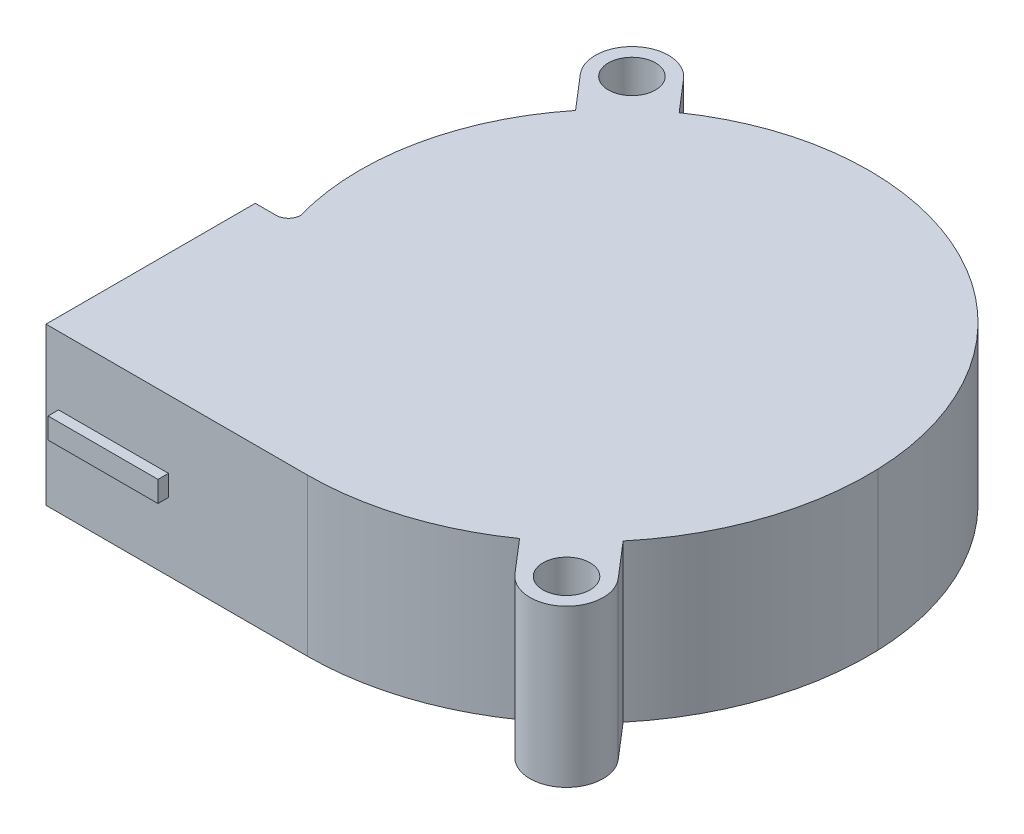
from build123d import *

# Parameters (mm, degrees)
BOSS_EXTRUDE1_DEPTH      = 7.5
BOSS_EXTRUDE1_DEPTH_BACK = 7.5
SKETCH1_R                = 2.25
BOSS_EXTRUDE2_DEPTH      = 1
BOSS_EXTRUDE2_DEPTH_BACK = 2
BOSS_EXTRUDE3_DEPTH      = 1
BOSS_EXTRUDE3_DEPTH_BACK = 1
SKETCH3_W                = 10.5
SKETCH3_H                = 1


with BuildPart() as part:
    # Sketch1 → Boss-Extrude1 (new, two sides: drawn at the far end of the back side and taken through both)
    with BuildSketch(Plane(origin=(0, 0, 0), x_dir=(1, 0, 0), z_dir=(0, 1, 0)).offset(-BOSS_EXTRUDE1_DEPTH_BACK)):
        with BuildLine():
            Line((0, -27.75), (-25, -27.75))
            Line((-25, -27.75), (-25, -7.75))
            Line((-25, -7.75), (-23, -7.75))
            ThreePointArc((-23, -7.75), (-22.173642142, -7.407711368), (-21.83135351, -6.58135351))
            ThreePointArc((-21.83135351, -6.58135351), (-22.519230493, -3.322579021), (-22.75, 0))
            ThreePointArc((-22.75, 0), (-21.367673649, 8.078905587), (-17.377967793, 15.238639437))
            Line((-17.377967793, 15.238639437), (-20.154237836, 18.468548377))
            ThreePointArc((-20.154237836, 18.468548377), (-19.781451623, 23.404237836), (-14.845762164, 23.031451623))
            Line((-14.845762164, 23.031451623), (-12.244288682, 20.004900775))
            ThreePointArc((-12.244288682, 20.004900775), (-6.410360065, 22.958761116), (0, 24.25))
            ThreePointArc((0, 24.25), (18.502982119, 17.781640069), (26.75, 0))
            ThreePointArc((26.75, 0), (25.310000225, -9.634196337), (20.525571791, -18.119512063))
            Line((20.525571791, -18.119512063), (23.404237836, -21.468548377))
            ThreePointArc((23.404237836, -21.468548377), (23.031451623, -26.404237836), (18.095762164, -26.031451623))
            Line((18.095762164, -26.031451623), (15.372148216, -22.862802716))
            ThreePointArc((15.372148216, -22.862802716), (8.06198842, -26.488798996), (0, -27.75))
        make_face()
        with Locations((-17.5, 20.75)):
            Circle(SKETCH1_R, mode=Mode.SUBTRACT)
        with Locations((20.75, -23.75)):
            Circle(SKETCH1_R, mode=Mode.SUBTRACT)
    extrude(amount=BOSS_EXTRUDE1_DEPTH + BOSS_EXTRUDE1_DEPTH_BACK)

    # Sketch2 → Boss-Extrude2 (add, two sides: drawn at the far end of the back side and taken through both)
    with BuildSketch(Plane(origin=(0, 0, 0), x_dir=(1, 0, 0), z_dir=(0, 1, 0)).offset(-BOSS_EXTRUDE2_DEPTH_BACK)):
        with BuildLine():
            Line((-23.375448552, 4.25), (-22.375448552, 4.25))
            Line((-22.375448552, 4.25), (-20.476060309, 3.242316336))
            Line((-20.476060309, 3.242316336), (-20.106924084, -2.963786455))
            Line((-20.106924084, -2.963786455), (-22.3712513, -4.25))
            Line((-22.3712513, -4.25), (-23.3712513, -4.25))
            add(Edge.make_bspline(
                [(-23.3712513, -4.25), (-24.126649893, -0.000369077), (-23.375448552, 4.25)],
                knots=[0, 0, 0, 1, 1, 1], degree=2))
        make_face()
    extrude(amount=BOSS_EXTRUDE2_DEPTH + BOSS_EXTRUDE2_DEPTH_BACK)

    # Sketch3 → Boss-Extrude3 (add, two sides: drawn at the far end of the back side and taken through both)
    with BuildSketch(Plane(origin=(0, 0, 0), x_dir=(1, 0, 0), z_dir=(0, 1, 0)).offset(-BOSS_EXTRUDE3_DEPTH_BACK)):
        with Locations((-18.55, -28.25)):
            Rectangle(SKETCH3_W, SKETCH3_H)
    extrude(amount=BOSS_EXTRUDE3_DEPTH + BOSS_EXTRUDE3_DEPTH_BACK)


solid = part.part
